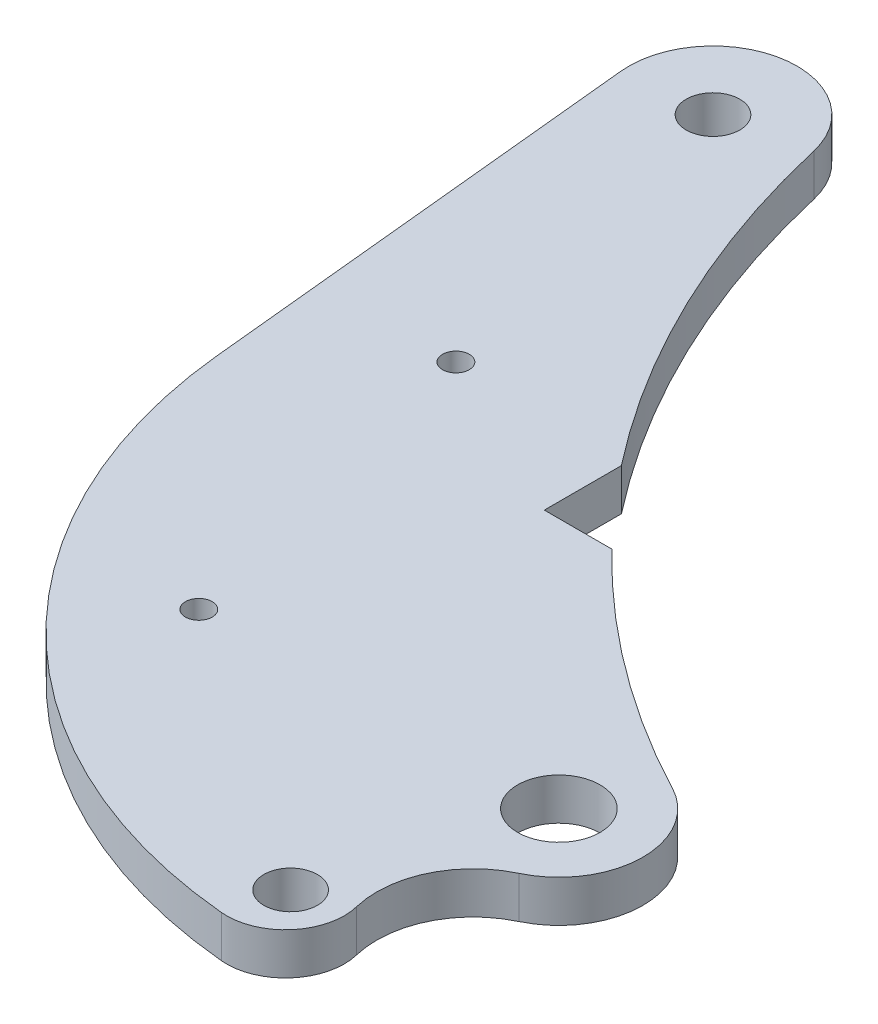
from build123d import *

# Parameters (mm, degrees)
SKETCH1_R           = 3.175
SKETCH1_R_2         = 4.8895
SKETCH1_R_3         = 1.5875
BOSS_EXTRUDE1_DEPTH = 2.4765


with BuildPart() as part:
    # Sketch1 → Boss-Extrude1 (new, symmetric)
    with BuildSketch(Plane(origin=(0, 0, 0), x_dir=(1, 0, 0), z_dir=(0, 1, 0))):
        with BuildLine():
            Line((-9.920693981, -0.985272137), (-4.645338625, -54.102765436))
            ThreePointArc((-4.645338625, -54.102765436), (13.82535886, -92.910530232), (52.781966192, -111.065199582))
            ThreePointArc((52.781966192, -111.065199582), (58.709905634, -108.665583198), (60.200009938, -102.446402065))
            ThreePointArc((60.200009938, -102.446402065), (60.977721367, -94.820202541), (66.399042003, -89.400512808))
            ThreePointArc((66.399042003, -89.400512808), (72.090603236, -80.589631254), (66.74806575, -71.56284909))
            ThreePointArc((66.74806575, -71.56284909), (51.849457493, -62.196647711), (38.60581081, -50.607856626))
            Line((38.60581081, -50.607856626), (30.607, -50.607856626))
            Line((30.607, -50.607856626), (30.607, -41.464916232))
            ThreePointArc((30.607, -41.464916232), (17.762693232, -20.754549727), (9.712854703, 2.24752837))
            ThreePointArc((9.712854703, 2.24752837), (-1.619737346, 9.837041282), (-9.920693981, -0.985272137))
        make_face()
        Circle(SKETCH1_R, mode=Mode.SUBTRACT)
        with Locations((62.123011123, -80.394598631)):
            Circle(SKETCH1_R_2, mode=Mode.SUBTRACT)
        with Locations((54.567235003, -104.644758367)):
            Circle(SKETCH1_R, mode=Mode.SUBTRACT)
        with Locations((10.16, -40.64)):
            Circle(SKETCH1_R_3, mode=Mode.SUBTRACT)
        with Locations((20.32, -81.28)):
            Circle(SKETCH1_R_3, mode=Mode.SUBTRACT)
    extrude(amount=BOSS_EXTRUDE1_DEPTH, both=True)


solid = part.part
